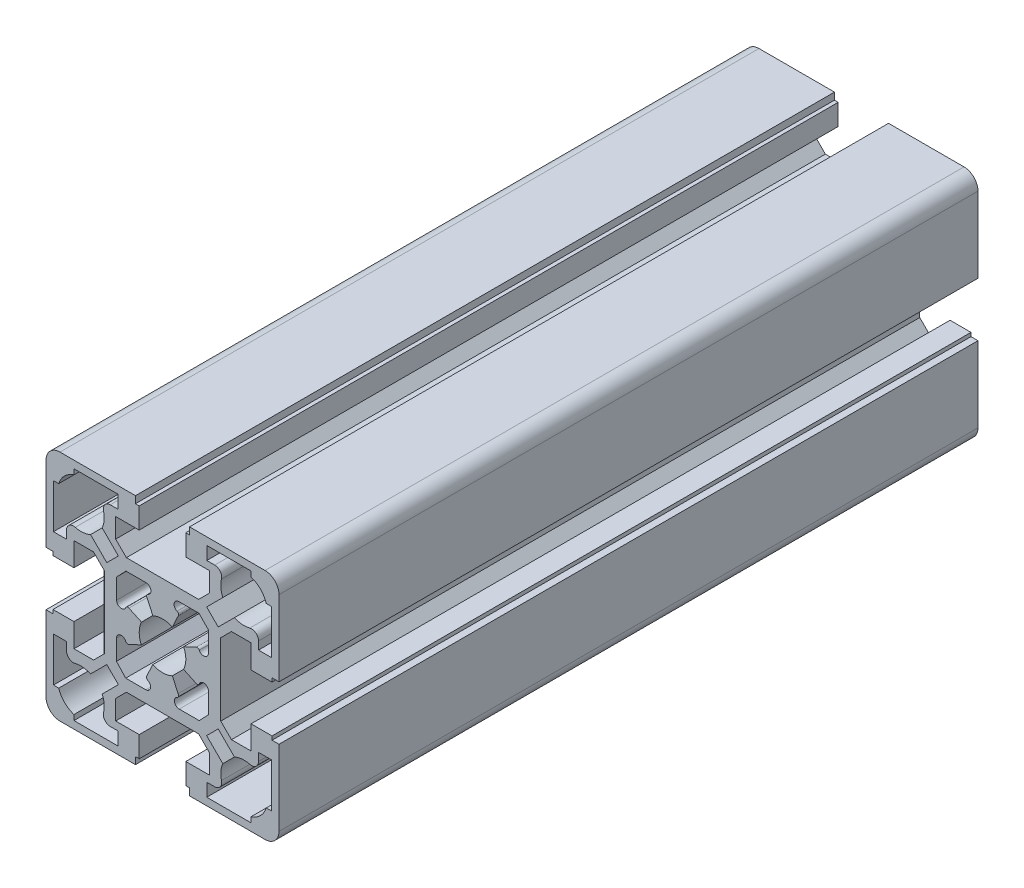
from build123d import *

# Parameters (mm, degrees)
BASE_EXTRUDE_DEPTH = 150


with BuildPart() as part:
    # Sketch1 → Base-Extrude (new body)
    with BuildSketch(Plane.XY):
        with BuildLine():
            Line((7.75, 12.5), (-7.75, 12.5))
            Line((-7.75, 12.5), (-10.05, 14.8))
            Line((-10.05, 14.8), (-10.05, 19))
            Line((-10.05, 19), (-5, 19))
            Line((-5, 19), (-5, 23.5))
            Line((-5, 23.5), (-5.8, 23.5))
            Line((-5.8, 23.5), (-5.8, 25))
            Line((-5.8, 25), (-22, 25))
            ThreePointArc((-22, 25), (-24.121320344, 24.121320344), (-25, 22))
            Line((-25, 22), (-25, 5.8))
            Line((-25, 5.8), (-23.5, 5.8))
            Line((-23.5, 5.8), (-23.5, 5))
            Line((-23.5, 5), (-19, 5))
            Line((-19, 5), (-19, 10.05))
            Line((-19, 10.05), (-14.8, 10.05))
            Line((-14.8, 10.05), (-12.5, 7.75))
            Line((-12.5, 7.75), (-12.5, -7.75))
            Line((-12.5, -7.75), (-14.8, -10.05))
            Line((-14.8, -10.05), (-19, -10.05))
            Line((-19, -10.05), (-19, -5))
            Line((-19, -5), (-23.5, -5))
            Line((-23.5, -5), (-23.5, -5.8))
            Line((-23.5, -5.8), (-25, -5.8))
            Line((-25, -5.8), (-25, -22))
            ThreePointArc((-25, -22), (-24.121320344, -24.121320344), (-22, -25))
            Line((-22, -25), (-5.8, -25))
            Line((-5.8, -25), (-5.8, -23.5))
            Line((-5.8, -23.5), (-5, -23.5))
            Line((-5, -23.5), (-5, -19))
            Line((-5, -19), (-10.05, -19))
            Line((-10.05, -19), (-10.05, -14.8))
            Line((-10.05, -14.8), (-7.75, -12.5))
            Line((-7.75, -12.5), (7.75, -12.5))
            Line((7.75, -12.5), (10.05, -14.8))
            Line((10.05, -14.8), (10.05, -19))
            Line((10.05, -19), (5, -19))
            Line((5, -19), (5, -23.5))
            Line((5, -23.5), (5.8, -23.5))
            Line((5.8, -23.5), (5.8, -25))
            Line((5.8, -25), (22, -25))
            ThreePointArc((22, -25), (24.121320344, -24.121320344), (25, -22))
            Line((25, -22), (25, -5.8))
            Line((25, -5.8), (23.5, -5.8))
            Line((23.5, -5.8), (23.5, -5))
            Line((23.5, -5), (19, -5))
            Line((19, -5), (19, -10.05))
            Line((19, -10.05), (14.8, -10.05))
            Line((14.8, -10.05), (12.5, -7.75))
            Line((12.5, -7.75), (12.5, 7.75))
            Line((12.5, 7.75), (14.8, 10.05))
            Line((14.8, 10.05), (19, 10.05))
            Line((19, 10.05), (19, 5))
            Line((19, 5), (23.5, 5))
            Line((23.5, 5), (23.5, 5.8))
            Line((23.5, 5.8), (25, 5.8))
            Line((25, 5.8), (25, 22))
            ThreePointArc((25, 22), (24.121320344, 24.121320344), (22, 25))
            Line((22, 25), (5.8, 25))
            Line((5.8, 25), (5.8, 23.5))
            Line((5.8, 23.5), (5, 23.5))
            Line((5, 23.5), (5, 19))
            Line((5, 19), (10.05, 19))
            Line((10.05, 19), (10.05, 14.8))
            Line((10.05, 14.8), (7.75, 12.5))
        make_face()
        with BuildLine():
            Line((3.505344903, 9.96577797), (7.822665473, 9.96577797))
            Line((7.822665473, 9.96577797), (9.85958722, 7.877775505))
            Line((9.85958722, 7.877775505), (9.850440617, 3.560464625))
            ThreePointArc((9.850440617, 3.560464625), (9.041479714, 2.556883244), (7.886596034, 3.129453777))
            Line((7.886596034, 3.129453777), (7.895357337, 3.110560702))
            ThreePointArc((7.895357337, 3.110560702), (7.613761881, 3.369695047), (7.231408173, 3.353812643))
            Line((7.231408173, 3.353812643), (4.535858613, 2.103802901))
            ThreePointArc((4.535858613, 2.103802901), (4.999987062, -0.011374477), (4.526239826, -2.124418281))
            Line((4.526239826, -2.124418281), (7.221789386, -3.374428023))
            ThreePointArc((7.221789386, -3.374428023), (7.604143095, -3.390310427), (7.885738551, -3.131176083))
            Line((7.885738551, -3.131176083), (7.907030563, -3.085261502))
            ThreePointArc((7.907030563, -3.085261502), (9.06210775, -2.511832674), (9.873011121, -3.514558784))
            Line((9.873011121, -3.514558784), (9.891304287, -7.831840598))
            Line((9.891304287, -7.831840598), (7.902556996, -9.96577797))
            Line((7.902556996, -9.96577797), (3.585236427, -9.96577797))
            ThreePointArc((3.585236427, -9.96577797), (2.578793519, -9.158022138), (3.149568198, -8.000605586))
            Line((3.149568198, -8.000605586), (3.18152755, -7.985702696))
            ThreePointArc((3.18152755, -7.985702696), (3.456201605, -7.650108756), (3.365281923, -7.226077224))
            Line((3.365281923, -7.226077224), (2.109564241, -4.533181964))
            ThreePointArc((2.109564241, -4.533181964), (0.010417022, -4.999989149), (-2.090657066, -4.541932742))
            Line((-2.090657066, -4.541932742), (-3.352077054, -7.232161617))
            ThreePointArc((-3.352077054, -7.232161617), (-3.44721565, -7.657355486), (-3.172730689, -7.995732769))
            Line((-3.172730689, -7.995732769), (-3.144425204, -8.009004913))
            ThreePointArc((-3.144425204, -8.009004913), (-2.57802929, -9.162157696), (-3.580406528, -9.96577797))
            Line((-3.580406528, -9.96577797), (-7.897727097, -9.96577797))
            Line((-7.897727097, -9.96577797), (-9.879549599, -7.825407892))
            Line((-9.879549599, -7.825407892), (-9.870402996, -3.508097012))
            ThreePointArc((-9.870402996, -3.508097012), (-9.064593686, -2.507341079), (-7.912547347, -3.076226227))
            Line((-7.912547347, -3.076226227), (-7.892788633, -3.118598925))
            ThreePointArc((-7.892788633, -3.118598925), (-7.610644812, -3.377136104), (-7.228325609, -3.360443688))
            Line((-7.228325609, -3.360443688), (-4.535430348, -2.104726005))
            ThreePointArc((-4.535430348, -2.104726005), (-4.999945915, 0.0232561), (-4.515655235, 2.146825051))
            Line((-4.515655235, 2.146825051), (-7.208550496, 3.402542734))
            ThreePointArc((-7.208550496, 3.402542734), (-7.590869698, 3.419235151), (-7.87301352, 3.160697971))
            Line((-7.87301352, 3.160697971), (-7.892726665, 3.118422996))
            ThreePointArc((-7.892726665, 3.118422996), (-9.044676902, 2.549585303), (-9.850418992, 3.550257755))
            Line((-9.850418992, 3.550257755), (-9.859565596, 7.867568635))
            Line((-9.859565596, 7.867568635), (-7.833159396, 9.96577797))
            Line((-7.833159396, 9.96577797), (-3.515838827, 9.96577797))
            ThreePointArc((-3.515838827, 9.96577797), (-2.513461589, 9.162157696), (-3.079857503, 8.009004913))
            Line((-3.079857503, 8.009004913), (-3.127507547, 7.986662309))
            ThreePointArc((-3.127507547, 7.986662309), (-3.398642875, 7.661708995), (-3.32345011, 7.245229618))
            Line((-3.32345011, 7.245229618), (-2.062030122, 4.555000744))
            ThreePointArc((-2.062030122, 4.555000744), (0.02615125, 4.999931611), (2.109564241, 4.533181964))
            Line((2.109564241, 4.533181964), (3.365281923, 7.226077224))
            ThreePointArc((3.365281923, 7.226077224), (3.436001626, 7.641565147), (3.163996416, 7.963504048))
            Line((3.163996416, 7.963504048), (3.072985785, 8.005708494))
            ThreePointArc((3.072985785, 8.005708494), (2.501750519, 9.159434003), (3.505344903, 9.96577797))
        make_face(mode=Mode.SUBTRACT)
        with BuildLine():
            Line((-23.4, -19), (-23.4, -9.5))
            Line((-23.4, -9.5), (-20.6, -9.5))
            Line((-20.6, -9.5), (-20.6, -11.199838588))
            ThreePointArc((-20.6, -11.199838588), (-20.020914539, -12.383864099), (-18.730778117, -12.653686998))
            ThreePointArc((-18.730778117, -12.653686998), (-17.057404686, -12.519470523), (-15.433920888, -12.946662588))
            Line((-15.433920888, -12.946662588), (-11.955404051, -9.46814575))
            Line((-11.955404051, -9.46814575), (-9.468145751, -11.955404051))
            Line((-9.468145751, -11.955404051), (-12.946662588, -15.433920888))
            ThreePointArc((-12.946662588, -15.433920888), (-12.519470523, -17.057404686), (-12.653686998, -18.730778117))
            ThreePointArc((-12.653686998, -18.730778117), (-12.383864099, -20.020914539), (-11.199838588, -20.6))
            Line((-11.199838588, -20.6), (-9.5, -20.6))
            Line((-9.5, -20.6), (-9.5, -23.4))
            Line((-9.5, -23.4), (-19, -23.4))
            Line((-19, -23.4), (-19, -22.269696007))
            ThreePointArc((-19, -22.269696007), (-21.035533906, -21.035533906), (-22.269696007, -19))
            Line((-22.269696007, -19), (-23.4, -19))
        make_face(mode=Mode.SUBTRACT)
        with BuildLine():
            Line((-23.4, 9.5), (-23.4, 19))
            Line((-23.4, 19), (-22.269696007, 19))
            ThreePointArc((-22.269696007, 19), (-21.035533906, 21.035533906), (-19, 22.269696007))
            Line((-19, 22.269696007), (-19, 23.4))
            Line((-19, 23.4), (-9.5, 23.4))
            Line((-9.5, 23.4), (-9.5, 20.6))
            Line((-9.5, 20.6), (-11.199838588, 20.6))
            ThreePointArc((-11.199838588, 20.6), (-12.383864099, 20.020914539), (-12.653686998, 18.730778117))
            ThreePointArc((-12.653686998, 18.730778117), (-12.519470523, 17.057404686), (-12.946662588, 15.433920888))
            Line((-12.946662588, 15.433920888), (-9.468145751, 11.955404051))
            Line((-9.468145751, 11.955404051), (-11.955404051, 9.46814575))
            Line((-11.955404051, 9.46814575), (-15.433920888, 12.946662588))
            ThreePointArc((-15.433920888, 12.946662588), (-17.057404686, 12.519470523), (-18.730778117, 12.653686998))
            ThreePointArc((-18.730778117, 12.653686998), (-20.020914539, 12.383864099), (-20.6, 11.199838588))
            Line((-20.6, 11.199838588), (-20.6, 9.5))
            Line((-20.6, 9.5), (-23.4, 9.5))
        make_face(mode=Mode.SUBTRACT)
        with BuildLine():
            Line((23.4, -9.5), (23.4, -19))
            Line((23.4, -19), (22.269696007, -19))
            ThreePointArc((22.269696007, -19), (21.035533906, -21.035533906), (19, -22.269696007))
            Line((19, -22.269696007), (19, -23.4))
            Line((19, -23.4), (9.5, -23.4))
            Line((9.5, -23.4), (9.5, -20.6))
            Line((9.5, -20.6), (11.199838588, -20.6))
            ThreePointArc((11.199838588, -20.6), (12.383864099, -20.020914539), (12.653686998, -18.730778117))
            ThreePointArc((12.653686998, -18.730778117), (12.519470523, -17.057404686), (12.946662588, -15.433920888))
            Line((12.946662588, -15.433920888), (9.468145751, -11.955404051))
            Line((9.468145751, -11.955404051), (11.955404051, -9.46814575))
            Line((11.955404051, -9.46814575), (15.433920888, -12.946662588))
            ThreePointArc((15.433920888, -12.946662588), (17.057404686, -12.519470523), (18.730778117, -12.653686998))
            ThreePointArc((18.730778117, -12.653686998), (20.020914539, -12.383864099), (20.6, -11.199838588))
            Line((20.6, -11.199838588), (20.6, -9.5))
            Line((20.6, -9.5), (23.4, -9.5))
        make_face(mode=Mode.SUBTRACT)
        with BuildLine():
            Line((23.4, 19), (23.4, 9.5))
            Line((23.4, 9.5), (20.6, 9.5))
            Line((20.6, 9.5), (20.6, 11.199838588))
            ThreePointArc((20.6, 11.199838588), (20.020914539, 12.383864099), (18.730778117, 12.653686998))
            ThreePointArc((18.730778117, 12.653686998), (17.057404686, 12.519470523), (15.433920888, 12.946662588))
            Line((15.433920888, 12.946662588), (11.955404051, 9.46814575))
            Line((11.955404051, 9.46814575), (9.46814575, 11.955404051))
            Line((9.46814575, 11.955404051), (12.946662588, 15.433920888))
            ThreePointArc((12.946662588, 15.433920888), (12.519470523, 17.057404686), (12.653686998, 18.730778117))
            ThreePointArc((12.653686998, 18.730778117), (12.383864099, 20.020914539), (11.199838588, 20.6))
            Line((11.199838588, 20.6), (9.5, 20.6))
            Line((9.5, 20.6), (9.5, 23.4))
            Line((9.5, 23.4), (19, 23.4))
            Line((19, 23.4), (19, 22.269696007))
            ThreePointArc((19, 22.269696007), (21.035533906, 21.035533906), (22.269696007, 19))
            Line((22.269696007, 19), (23.4, 19))
        make_face(mode=Mode.SUBTRACT)
    extrude(amount=-BASE_EXTRUDE_DEPTH)


solid = part.part
